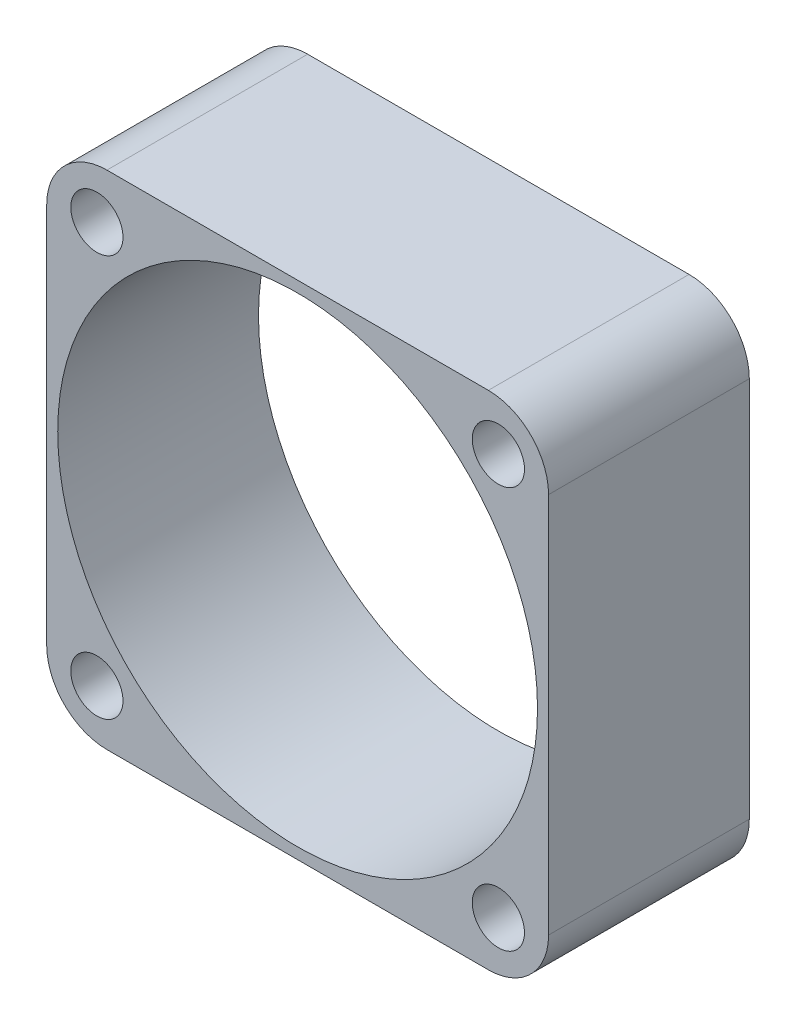
from build123d import *

# Parameters (mm, degrees)
SKETCH1_W           = 25
SKETCH1_H           = 25
BOSS_EXTRUDE1_DEPTH = 10
FILLET1_R           = 3
SKETCH2_R           = 1.3
CUT_EXTRUDE1_DEPTH  = 10
SKETCH3_R           = 11.95
CUT_EXTRUDE2_DEPTH  = 10


with BuildPart() as part:
    # Sketch1 → Boss-Extrude1 (new body)
    with BuildSketch(Plane.XY):
        with Locations((-25.324193791, -75.114139951)):
            Rectangle(SKETCH1_W, SKETCH1_H)
    extrude(amount=BOSS_EXTRUDE1_DEPTH)

    # Fillet1
    fillet1_edges = [part.edges().sort_by_distance(p)[0] for p in [
        (-12.824193791, -87.614139951, 5),
        (-37.824193791, -87.614139951, 5),
        (-37.824193791, -62.614139951, 5),
        (-12.824193791, -62.614139951, 5),
    ]]
    fillet(fillet1_edges, radius=FILLET1_R)

    # Sketch2 → Cut-Extrude1 (cut)
    with BuildSketch(Plane.XY.offset(10)):
        with Locations((-15.324193791, -85.114139951)):
            Circle(SKETCH2_R)
        with Locations((-15.324193791, -65.114139951)):
            Circle(SKETCH2_R)
        with Locations((-35.324193791, -65.114139951)):
            Circle(SKETCH2_R)
        with Locations((-35.324193791, -85.114139951)):
            Circle(SKETCH2_R)
    extrude(amount=-CUT_EXTRUDE1_DEPTH, mode=Mode.SUBTRACT)

    # Sketch3 → Cut-Extrude2 (cut)
    with BuildSketch(Plane.XY.offset(10)):
        with Locations((-25.324193791, -75.114139951)):
            Circle(SKETCH3_R)
    extrude(amount=-CUT_EXTRUDE2_DEPTH, mode=Mode.SUBTRACT)


solid = part.part
